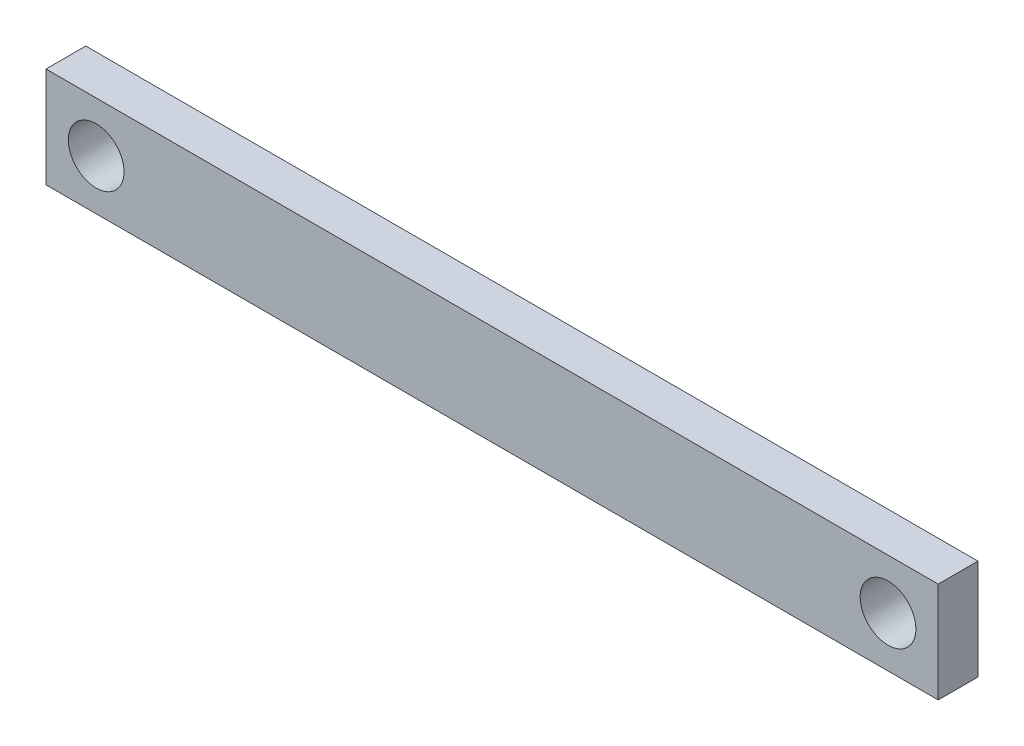
from build123d import *

# Parameters (mm, degrees)
SKETCH1_W      = 56.962
SKETCH1_H      = 6.406
SKETCH1_R      = 1.778
SPREADER_DEPTH = 2.54


with BuildPart() as part:
    # Sketch1 → Spreader (new body)
    with BuildSketch(Plane.XY):
        Rectangle(SKETCH1_W, SKETCH1_H)
        with Locations((-25.278, 0)):
            Circle(SKETCH1_R, mode=Mode.SUBTRACT)
        with Locations((25.278, 0)):
            Circle(SKETCH1_R, mode=Mode.SUBTRACT)
    extrude(amount=SPREADER_DEPTH)


solid = part.part
